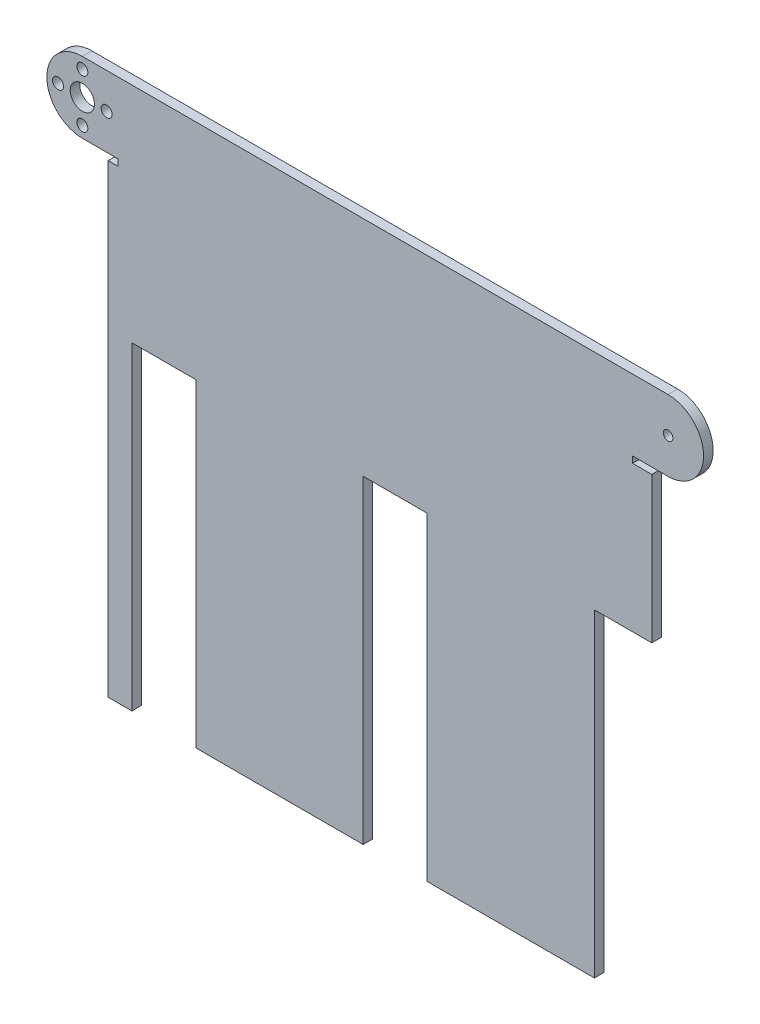
from build123d import *

# Parameters (mm, degrees)
ESQUISSE1_R        = 1.5
ESQUISSE1_R_2      = 3.8
ESQUISSE1_R_3      = 1.725
BOSS_EXTRU_1_DEPTH = 3


with BuildPart() as part:
    # Esquisse1 → Boss.-Extru.1 (new body)
    with BuildSketch(Plane.XY):
        with BuildLine():
            Line((19.21041076, -67.22505422), (26.66041076, -67.22505422))
            Line((26.66041076, -67.22505422), (26.66041076, 32.77494578))
            Line((26.66041076, 32.77494578), (46.66041076, 32.77494578))
            Line((46.66041076, 32.77494578), (46.66041076, -67.22505422))
            Line((46.66041076, -67.22505422), (99.16041076, -67.22505422))
            Line((99.16041076, -67.22505422), (99.16041076, 32.77494578))
            Line((99.16041076, 32.77494578), (119.16041076, 32.77494578))
            Line((119.16041076, 32.77494578), (119.16041076, -67.22505422))
            Line((119.16041076, -67.22505422), (171.66041076, -67.22505422))
            Line((171.66041076, -67.22505422), (171.66041076, 32.77494578))
            Line((171.66041076, 32.77494578), (189.66041076, 32.77494578))
            Line((189.66041076, 32.77494578), (189.66041076, 78.53494578))
            Line((189.66041076, 78.53494578), (183.66041076, 78.53494578))
            Line((183.66041076, 78.53494578), (183.66041076, 80.53494578))
            Line((183.66041076, 80.53494578), (194.78041076, 80.53494578))
            ThreePointArc((194.78041076, 80.53494578), (205.90041076, 91.65494578), (194.78041076, 102.77494578))
            Line((194.78041076, 102.77494578), (11.09041076, 102.77494578))
            ThreePointArc((11.09041076, 102.77494578), (-0.02958924, 91.65494578), (11.09041076, 80.53494578))
            Line((11.09041076, 80.53494578), (22.21041076, 80.53494578))
            Line((22.21041076, 80.53494578), (22.21041076, 78.53494578))
            Line((22.21041076, 78.53494578), (19.21041076, 78.53494578))
            Line((19.21041076, 78.53494578), (19.21041076, -67.22505422))
        make_face()
        with Locations((194.78041076, 91.65494578)):
            Circle(ESQUISSE1_R, mode=Mode.SUBTRACT)
        with Locations((11.09041076, 91.65494578)):
            Circle(ESQUISSE1_R_2, mode=Mode.SUBTRACT)
        with Locations((11.09041076, 99.26494578)):
            Circle(ESQUISSE1_R_3, mode=Mode.SUBTRACT)
        with Locations((18.70041076, 91.65494578)):
            Circle(ESQUISSE1_R_3, mode=Mode.SUBTRACT)
        with Locations((11.09041076, 84.04494578)):
            Circle(ESQUISSE1_R_3, mode=Mode.SUBTRACT)
        with Locations((3.48041076, 91.65494578)):
            Circle(ESQUISSE1_R_3, mode=Mode.SUBTRACT)
    extrude(amount=BOSS_EXTRU_1_DEPTH)


solid = part.part
